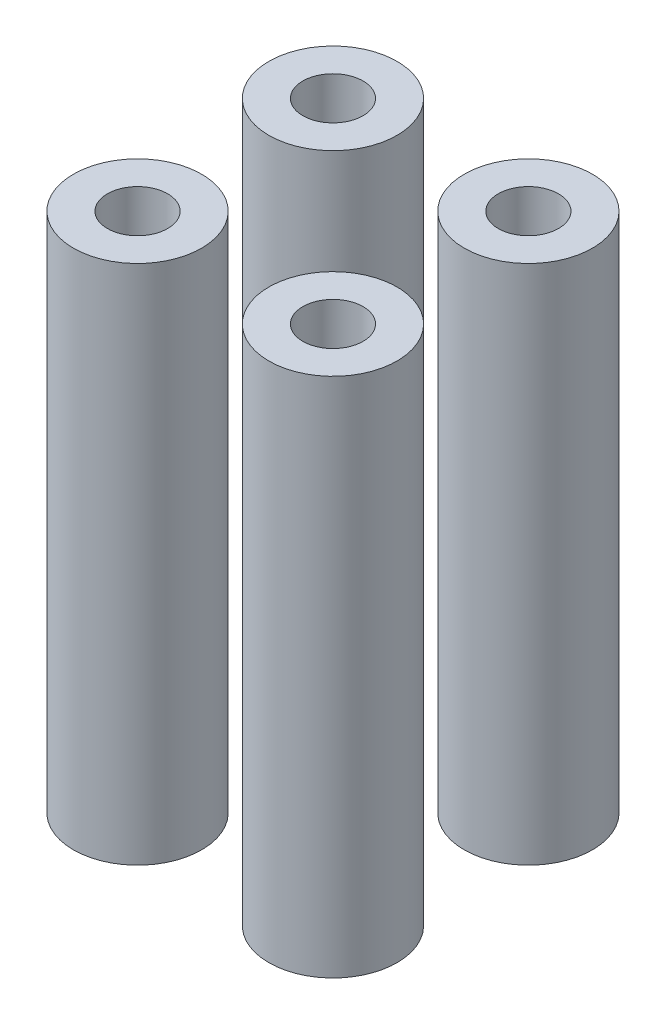
from build123d import *

# Parameters (mm, degrees)
SKETCH2_R           = 2.5
BOSS_EXTRUDE2_DEPTH = 20.32
SKETCH4_R           = 1.175
CUT_EXTRUDE1_DEPTH  = 6.35
LPATTERN1_COUNT     = 2
LPATTERN1_PITCH     = 7.62
LPATTERN1_2_COUNT   = 2
LPATTERN1_2_PITCH   = 7.62


with BuildPart() as part:
    # Sketch2 → Boss-Extrude2 (new body)
    with BuildSketch(Plane(origin=(0, 0, 0), x_dir=(1, 0, 0), z_dir=(0, 1, 0))):
        Circle(SKETCH2_R)
    extrude(amount=BOSS_EXTRUDE2_DEPTH)

    # Sketch4 → Cut-Extrude1 (cut)
    with BuildSketch(Plane(origin=(0, 20.32, 0), x_dir=(1, 0, 0), z_dir=(0, 1, 0))):
        Circle(SKETCH4_R)
    extrude(amount=-CUT_EXTRUDE1_DEPTH, mode=Mode.SUBTRACT)


with BuildPart() as lpattern1_1:
    # LPattern1: pattern copy
    add(part.part.moved(Location(Vector(0, 0, 1) * (1 * LPATTERN1_PITCH))))


with BuildPart() as lpattern1_2_1:
    # LPattern1 2: pattern copy
    add(part.part.moved(Location(Vector(1, 0, 0) * (1 * LPATTERN1_2_PITCH))))


with BuildPart() as lpattern1_2_2:
    # LPattern1 2: pattern copy
    add(lpattern1_1.part.moved(Location(Vector(1, 0, 0) * (1 * LPATTERN1_2_PITCH))))


solid = Compound([part.part, lpattern1_1.part, lpattern1_2_1.part, lpattern1_2_2.part])
